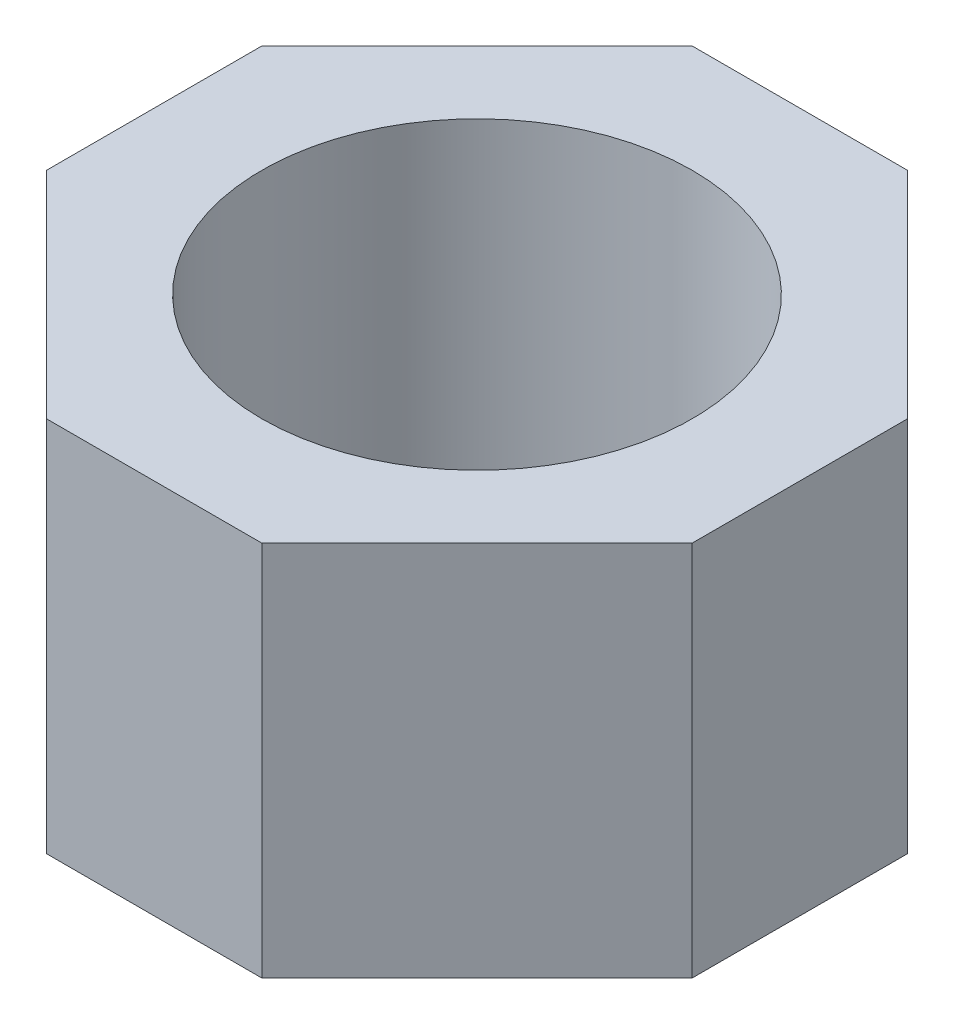
from build123d import *

# Parameters (mm, degrees)
BOSS_EXTRUDE1_DEPTH = 35
SKETCH2_R           = 20
CUT_EXTRUDE1_DEPTH  = 36


with BuildPart() as part:
    # Sketch1 → Boss-Extrude1 (new body)
    with BuildSketch(Plane(origin=(0, 0, 0), x_dir=(1, 0, 0), z_dir=(0, 1, 0))):
        Polygon((30, 10), (10, 30), (-10, 30), (-30, 10), (-30, -10), (-10, -30), (10, -30), (30, -10), align=None)
    extrude(amount=BOSS_EXTRUDE1_DEPTH)

    # Sketch2 → Cut-Extrude1 (cut, through all)
    with BuildSketch(Plane(origin=(0, 35, 0), x_dir=(1, 0, 0), z_dir=(0, 1, 0))):
        Circle(SKETCH2_R)
    extrude(amount=-CUT_EXTRUDE1_DEPTH, mode=Mode.SUBTRACT)


solid = part.part
